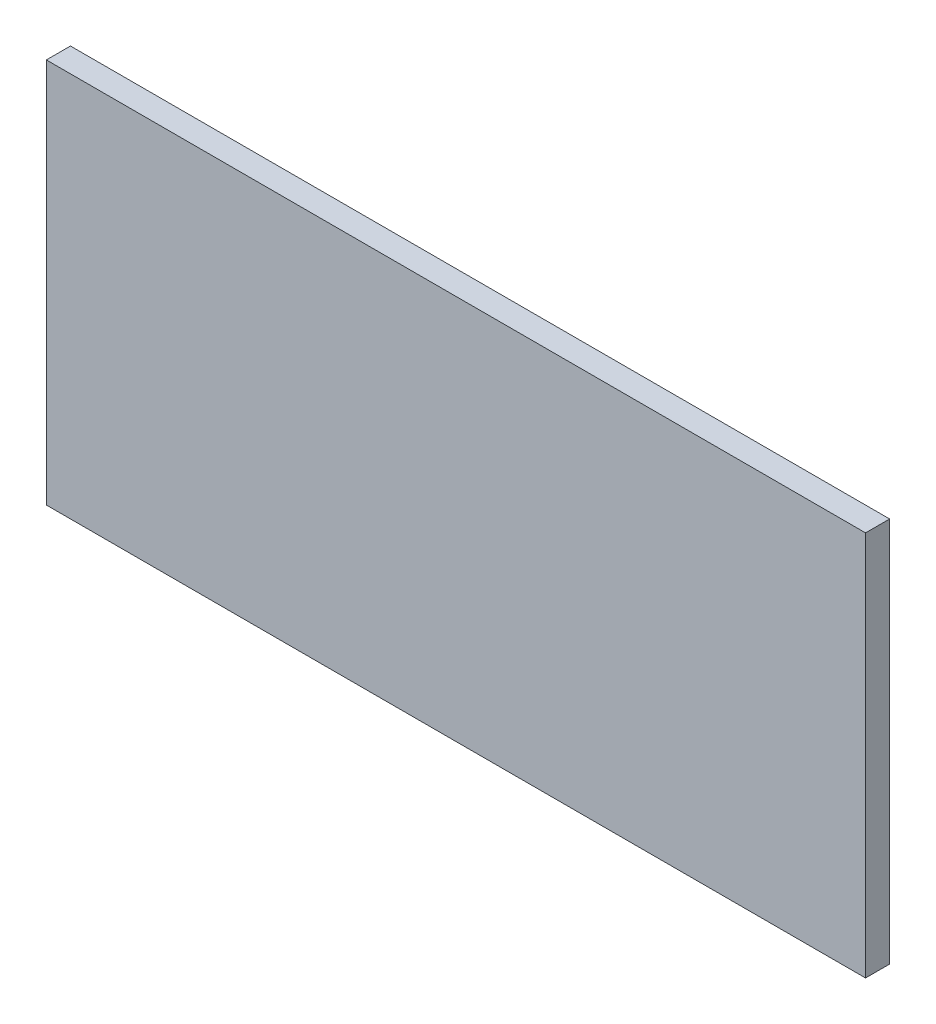
from build123d import *

# Parameters (mm, degrees)
SKETCH1_W           = 107.95
SKETCH1_H           = 50.8
BOSS_EXTRUDE1_DEPTH = 3.175


with BuildPart() as part:
    # Sketch1 → Boss-Extrude1 (new body)
    with BuildSketch(Plane.XY):
        Rectangle(SKETCH1_W, SKETCH1_H)
    extrude(amount=BOSS_EXTRUDE1_DEPTH)


solid = part.part
